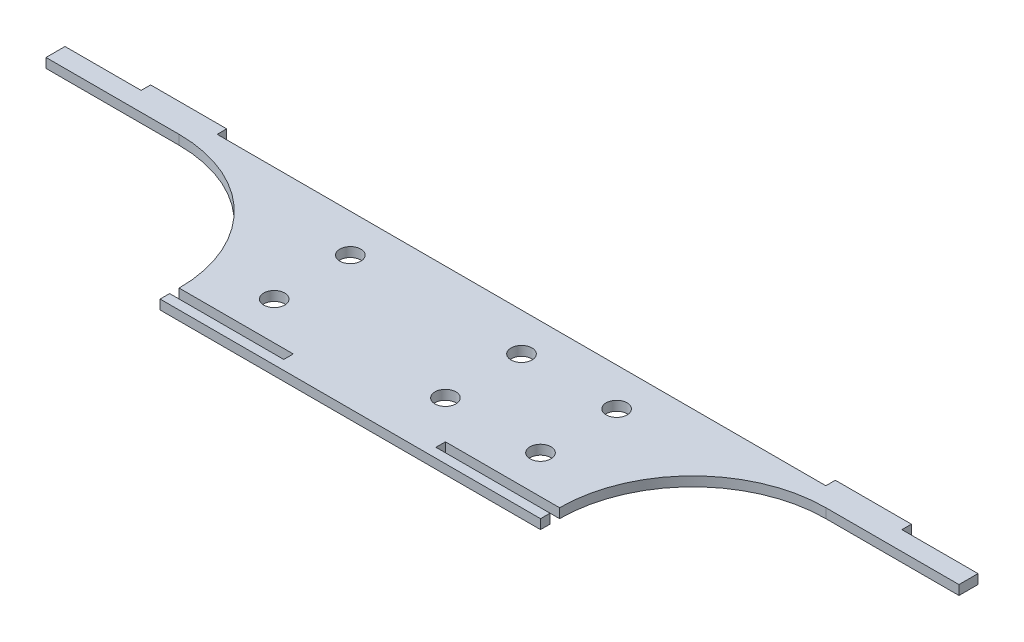
from build123d import *

# Parameters (mm, degrees)
SKETCH1_R           = 3.5
BOSS_EXTRUDE1_DEPTH = 3.175


with BuildPart() as part:
    # Sketch1 → Boss-Extrude1 (new body)
    with BuildSketch(Plane(origin=(0, 0, 0), x_dir=(1, 0, 0), z_dir=(0, 1, 0))):
        with BuildLine():
            Line((-152.4, 19.05), (-107.95, 19.05))
            ThreePointArc((-107.95, 19.05), (-76.519103576, 6.030896424), (-63.5, -25.4))
            Line((-63.5, -25.4), (-25.4, -25.4))
            Line((-25.4, -25.4), (-25.4, -28.575))
            Line((-25.4, -28.575), (-63.5, -28.575))
            Line((-63.5, -28.575), (-63.5, -31.75))
            Line((-63.5, -31.75), (63.5, -31.75))
            Line((63.5, -31.75), (63.5, -28.575))
            Line((63.5, -28.575), (25.4, -28.575))
            Line((25.4, -28.575), (25.4, -25.4))
            Line((25.4, -25.4), (63.5, -25.4))
            ThreePointArc((63.5, -25.4), (76.519103576, 6.030896424), (107.95, 19.05))
            Line((107.95, 19.05), (152.4, 19.05))
            Line((152.4, 19.05), (152.4, 25.4))
            Line((152.4, 25.4), (127, 25.4))
            Line((127, 25.4), (127, 28.575))
            Line((127, 28.575), (101.6, 28.575))
            Line((101.6, 28.575), (101.6, 25.4))
            Line((101.6, 25.4), (-101.6, 25.4))
            Line((-101.6, 25.4), (-101.6, 28.575))
            Line((-101.6, 28.575), (-127, 28.575))
            Line((-127, 28.575), (-127, 25.4))
            Line((-127, 25.4), (-152.4, 25.4))
            Line((-152.4, 25.4), (-152.4, 19.05))
        make_face()
        with Locations((-44.45, -12.7)):
            Circle(SKETCH1_R, mode=Mode.SUBTRACT)
        with Locations((12.7, -12.7)):
            Circle(SKETCH1_R, mode=Mode.SUBTRACT)
        with Locations((44.45, -12.7)):
            Circle(SKETCH1_R, mode=Mode.SUBTRACT)
        with Locations((-44.45, 12.7)):
            Circle(SKETCH1_R, mode=Mode.SUBTRACT)
        with Locations((12.7, 12.7)):
            Circle(SKETCH1_R, mode=Mode.SUBTRACT)
        with Locations((44.45, 12.7)):
            Circle(SKETCH1_R, mode=Mode.SUBTRACT)
    extrude(amount=BOSS_EXTRUDE1_DEPTH)


solid = part.part
